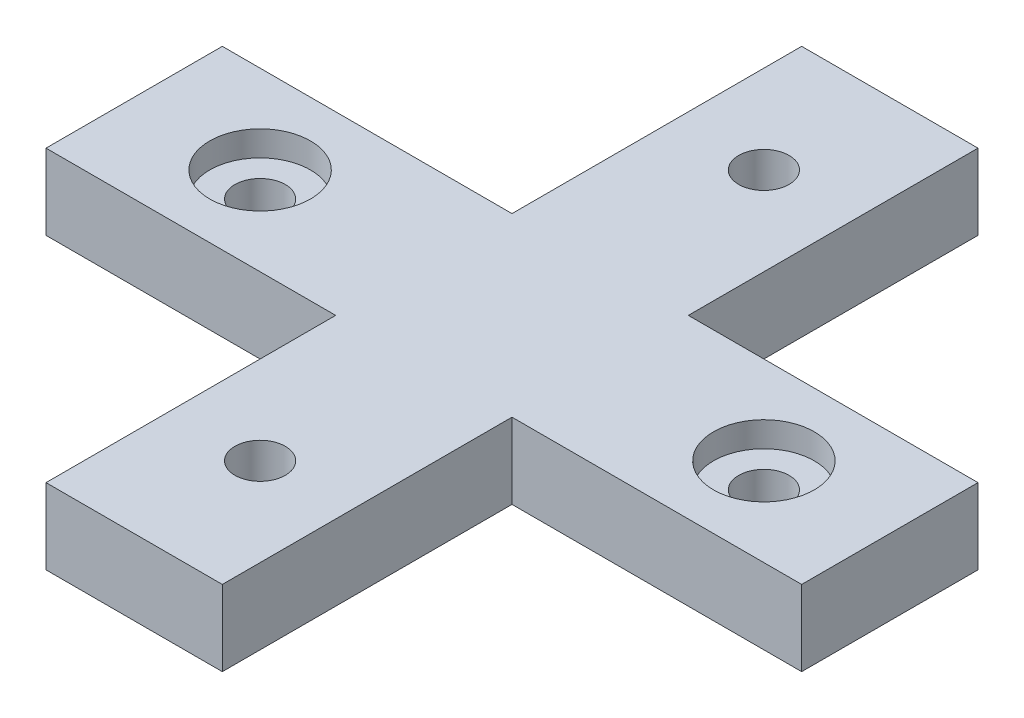
from build123d import *

# Parameters (mm, degrees)
SKETCH1_R           = 2
SKETCH1_R_2         = 1
BOSS_EXTRUDE1_DEPTH = 3
SKETCH1_3_R         = 2
SKETCH1_3_R_2       = 1
BOSS_EXTRUDE2_DEPTH = 2


with BuildPart() as part:
    # Sketch1 → Boss-Extrude1 (new body)
    with BuildSketch(Plane(origin=(0, 0, 0), x_dir=(1, 0, 0), z_dir=(0, 1, 0))):
        Polygon((-3.5, 3.5), (-15, 3.5), (-15, -3.5), (-3.5, -3.5), (-3.5, -15), (3.5, -15), (3.5, -3.5), (15, -3.5), (15, 3.5), (3.5, 3.5), (3.5, 15), (-3.5, 15), align=None)
        with Locations((-10, 0)):
            Circle(SKETCH1_R, mode=Mode.SUBTRACT)
        with Locations((10, 0)):
            Circle(SKETCH1_R, mode=Mode.SUBTRACT)
        with Locations((0, 10)):
            Circle(SKETCH1_R_2, mode=Mode.SUBTRACT)
        with Locations((0, -10)):
            Circle(SKETCH1_R_2, mode=Mode.SUBTRACT)
    extrude(amount=BOSS_EXTRUDE1_DEPTH)

    # Sketch1_3 → Boss-Extrude2 (add)
    # profile 1 of 2: a face of its own
    with BuildSketch(Plane(origin=(0, 0, 0), x_dir=(1, 0, 0), z_dir=(0, 1, 0))):
        with Locations((10, 0)):
            Circle(SKETCH1_3_R)
        with Locations((10, 0)):
            Circle(SKETCH1_3_R_2, mode=Mode.SUBTRACT)
    # profile 2 of 2: a face of its own
    with BuildSketch(Plane(origin=(0, 0, 0), x_dir=(1, 0, 0), z_dir=(0, 1, 0))):
        with Locations((-10, 0)):
            Circle(SKETCH1_3_R)
        with Locations((-10, 0)):
            Circle(SKETCH1_3_R_2, mode=Mode.SUBTRACT)
    extrude(amount=BOSS_EXTRUDE2_DEPTH)


solid = part.part
